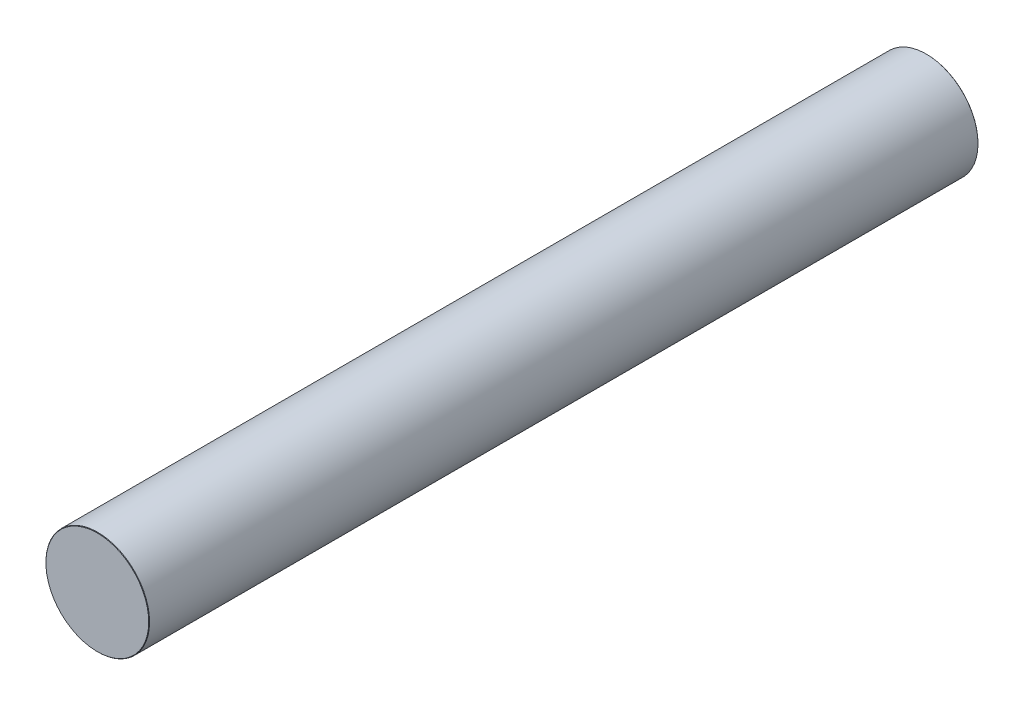
from build123d import *

# Parameters (mm, degrees)
SKETCH_1_R      = 12.5
EXTRUDE_1_DEPTH = 200
CHAMFER_1_SIZE  = 0.1


with BuildPart() as part:
    # Эскиз1 → Бобышка-Вытянуть1 (new body)
    with BuildSketch(Plane.XY):
        Circle(SKETCH_1_R)
    extrude(amount=EXTRUDE_1_DEPTH)

    # Фаска1
    chamfer_1_edges = [part.edges().sort_by_distance(p)[0] for p in [
        (-12.5, 0, 0),
        (-12.5, 0, 200),
    ]]
    chamfer(chamfer_1_edges, length=CHAMFER_1_SIZE)


solid = part.part
